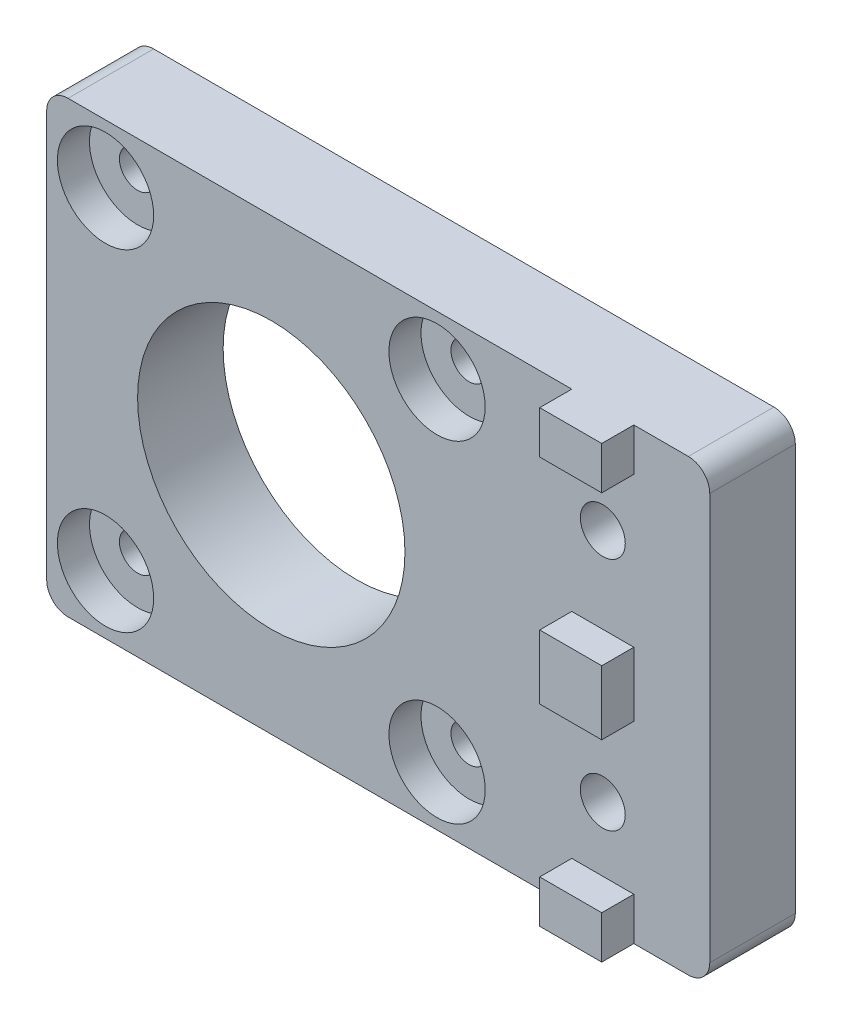
from build123d import *

# Parameters (mm, degrees)
ESQUISSE1_W             = 62
ESQUISSE1_H             = 42
BOSS_EXTRU_1_DEPTH      = 8
ESQUISSE2_R             = 2.1
ESQUISSE2_R_2           = 12.5
ESQUISSE2_R_3           = 1.7
ENL_V_MAT_EXTRU_1_DEPTH = 9
ESQUISSE3_W             = 5.8
ESQUISSE3_H             = 4
ESQUISSE3_H_2           = 6
BOSS_EXTRU_2_DEPTH      = 3
CONG_1_R                = 2
ESQUISSE4_R             = 4.5
ENL_V_MAT_EXTRU_2_DEPTH = 3


with BuildPart() as part:
    # Esquisse1 → Boss.-Extru.1 (new body)
    with BuildSketch(Plane.XY):
        Rectangle(ESQUISSE1_W, ESQUISSE1_H)
    extrude(amount=BOSS_EXTRU_1_DEPTH)

    # Esquisse2 → Enlèv. mat.-Extru.1 (cut, through all)
    with BuildSketch(Plane.XY.offset(8)):
        with Locations((21, 11)):
            Circle(ESQUISSE2_R)
        with Locations((21, -11)):
            Circle(ESQUISSE2_R)
        with Locations((-10, 0)):
            Circle(ESQUISSE2_R_2)
        with Locations((-25.5, 15.5)):
            Circle(ESQUISSE2_R_3)
        with Locations((5.5, 15.5)):
            Circle(ESQUISSE2_R_3)
        with Locations((5.5, -15.5)):
            Circle(ESQUISSE2_R_3)
        with Locations((-25.5, -15.5)):
            Circle(ESQUISSE2_R_3)
    extrude(amount=-ENL_V_MAT_EXTRU_1_DEPTH, mode=Mode.SUBTRACT)

    # Esquisse3 → Boss.-Extru.2 (add)
    with BuildSketch(Plane.XY.offset(8)):
        with Locations((21, 19)):
            Rectangle(ESQUISSE3_W, ESQUISSE3_H)
        with Locations((21, -19)):
            Rectangle(ESQUISSE3_W, ESQUISSE3_H)
        with Locations((21, 0)):
            Rectangle(ESQUISSE3_W, ESQUISSE3_H_2)
    extrude(amount=BOSS_EXTRU_2_DEPTH)

    # Congé1
    cong_1_edges = [part.edges().sort_by_distance(p)[0] for p in [
        (-31, 21, 4),
        (-31, -21, 4),
        (31, 21, 4),
        (31, -21, 4),
    ]]
    fillet(cong_1_edges, radius=CONG_1_R)

    # Esquisse4 → Enlèv. mat.-Extru.2 (cut)
    with BuildSketch(Plane.XY.offset(8)):
        with Locations((-25.5, 15.5)):
            Circle(ESQUISSE4_R)
        with Locations((-25.5, -15.5)):
            Circle(ESQUISSE4_R)
        with Locations((5.5, -15.5)):
            Circle(ESQUISSE4_R)
        with Locations((5.5, 15.5)):
            Circle(ESQUISSE4_R)
    extrude(amount=-ENL_V_MAT_EXTRU_2_DEPTH, mode=Mode.SUBTRACT)


solid = part.part
